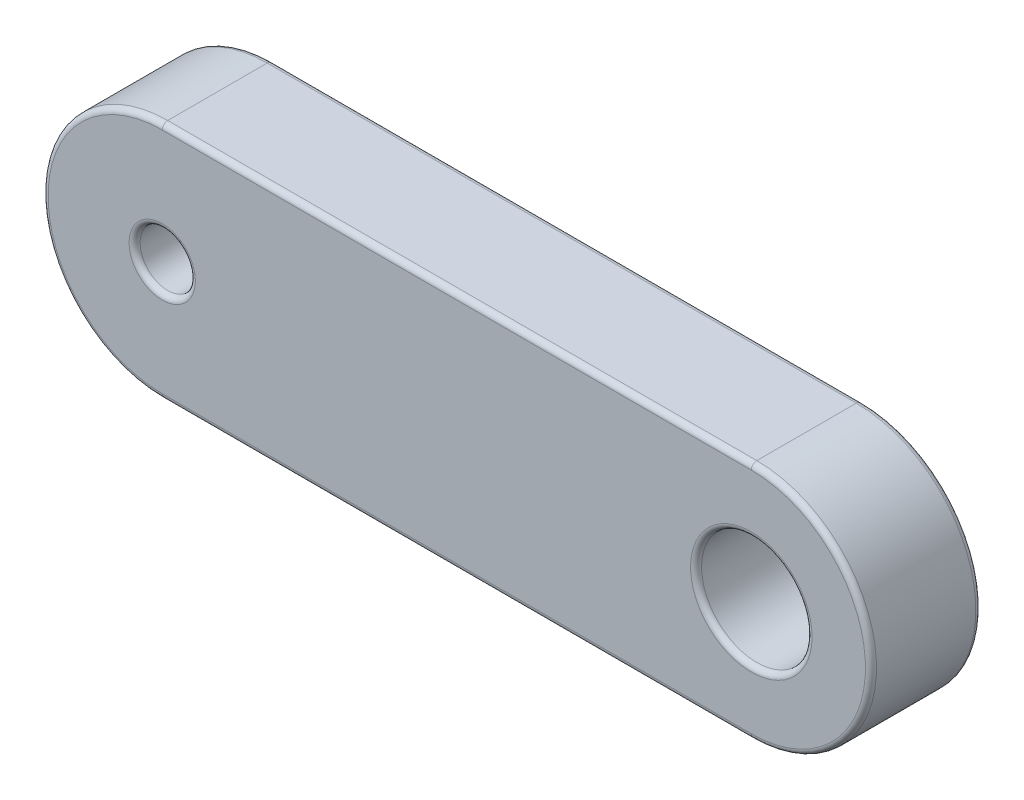
from build123d import *

# Parameters (mm, degrees)
SKETCH1_R           = 0.75
SKETCH1_R_2         = 1.5
BOSS_EXTRUDE1_DEPTH = 1.5
FILLET1_R           = 0.15


with BuildPart() as part:
    # Sketch1 → Boss-Extrude1 (new body, symmetric)
    with BuildSketch(Plane.XY):
        with BuildLine():
            Line((-8, 3.25), (8, 3.25))
            ThreePointArc((8, 3.25), (11.25, 0), (8, -3.25))
            Line((8, -3.25), (-8, -3.25))
            ThreePointArc((-8, -3.25), (-11.25, 0), (-8, 3.25))
        make_face()
        with Locations((-8, 0)):
            Circle(SKETCH1_R, mode=Mode.SUBTRACT)
        with Locations((8, 0)):
            Circle(SKETCH1_R_2, mode=Mode.SUBTRACT)
    extrude(amount=BOSS_EXTRUDE1_DEPTH, both=True)

    # Fillet1
    fillet1_edges = [part.edges().sort_by_distance(p)[0] for p in [
        (-8.75, 0, -1.5),
        (-8.75, 0, 1.5),
        (11.25, 0, 1.5),
        (6.5, 0, -1.5),
        (6.5, 0, 1.5),
        (0, 3.25, 1.5),
        (-11.25, 0, 1.5),
        (0, 3.25, -1.5),
        (11.25, 0, -1.5),
        (0, -3.25, -1.5),
        (-11.25, 0, -1.5),
        (0, -3.25, 1.5),
    ]]
    fillet(fillet1_edges, radius=FILLET1_R)


solid = part.part
